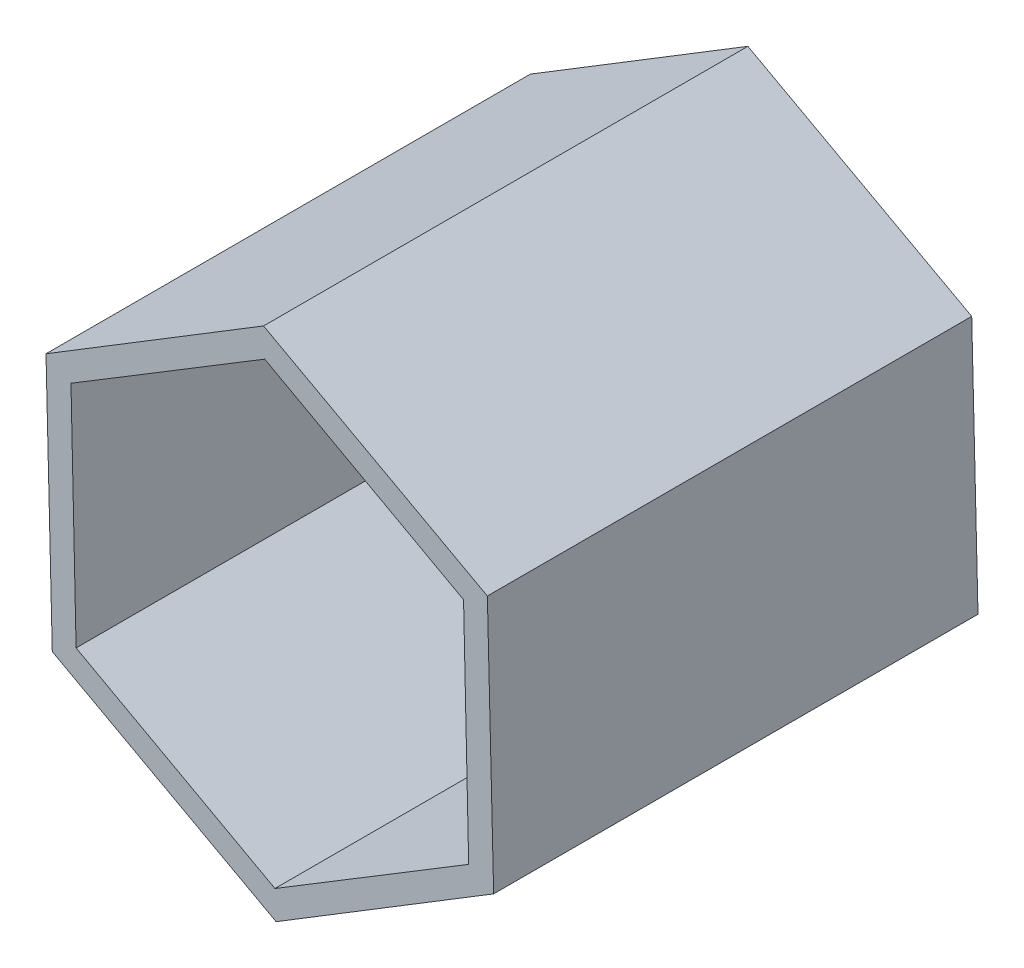
from build123d import *

# Parameters (mm, degrees)
BOSS_EXTRUDE1_DEPTH = 127
CUT_EXTRUDE1_DEPTH  = 127


with BuildPart() as part:
    # Sketch1 → Boss-Extrude1 (new body)
    with BuildSketch(Plane.XY):
        Polygon((57.041390795, 34.836612302), (-1.648695838, 66.817599647), (-58.690086633, 31.980987345), (-57.041390795, -34.836612302), (1.648695838, -66.817599647), (58.690086633, -31.980987345), align=None)
    extrude(amount=BOSS_EXTRUDE1_DEPTH)

    # Sketch2 → Cut-Extrude1 (cut)
    with BuildSketch(Plane.XY.offset(127)):
        Polygon((50.799126685, 30.879388059), (-1.34277117, 59.433028229), (-52.141897855, 28.55364017), (-50.799126685, -30.879388059), (1.34277117, -59.433028229), (52.141897855, -28.55364017), align=None)
    extrude(amount=-CUT_EXTRUDE1_DEPTH, mode=Mode.SUBTRACT)


solid = part.part
